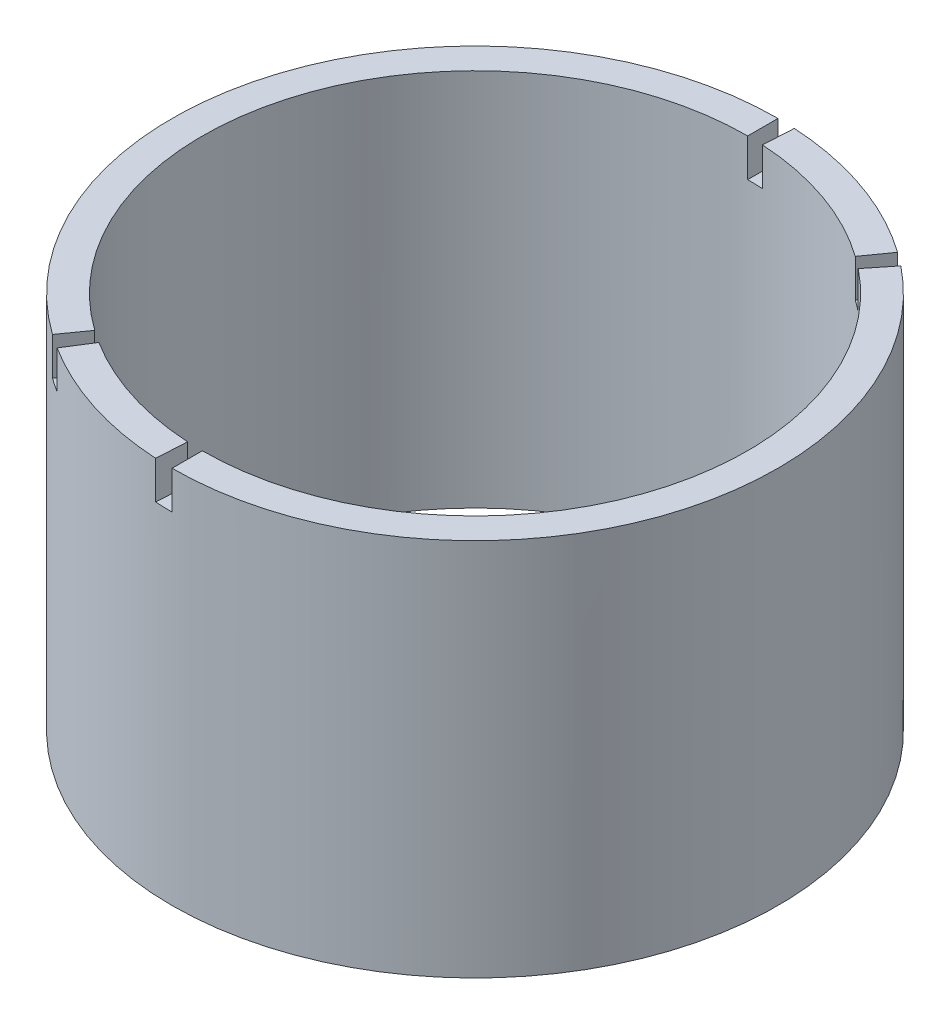
from build123d import *

# Parameters (mm, degrees)
ESQUISSE1_R      = 40
ESQUISSE1_R_2    = 36
EXTRUSION1_DEPTH = 50
EXTRUSION2_DEPTH = 5


with BuildPart() as part:
    # Esquisse1 → Extrusion1 (new body)
    with BuildSketch(Plane(origin=(0, 0, 0), x_dir=(1, 0, 0), z_dir=(0, 1, 0))):
        Circle(ESQUISSE1_R)
        Circle(ESQUISSE1_R_2, mode=Mode.SUBTRACT)
    extrude(amount=EXTRUSION1_DEPTH)

    # Esquisse2 → Extrusion2 (cut)
    with BuildSketch(Plane(origin=(0, 50, 0), x_dir=(1, 0, 0), z_dir=(0, 1, 0))):
        with BuildLine():
            Line((0, -40), (0, -36))
            ThreePointArc((0, -36), (-1.000386324, -35.986097693), (-2, -35.944401511))
            Line((-2, -35.944401511), (-2.222222222, -39.938223901))
            ThreePointArc((-2.222222222, -39.938223901), (-1.11154036, -39.984552993), (0, -40))
        make_face()
        with BuildLine():
            Line((0, 40), (0, 36))
            ThreePointArc((0, 36), (1.000386324, 35.986097693), (2, 35.944401511))
            Line((2, 35.944401511), (2.222222222, 39.938223901))
            ThreePointArc((2.222222222, 39.938223901), (1.11154036, 39.984552993), (0, 40))
        make_face()
        with BuildLine():
            Line((23.193991942, 32.588935819), (20.874592748, 29.330042237))
            ThreePointArc((20.874592748, 29.330042237), (21.68126112, 28.738874652), (22.471196895, 28.12552773))
            Line((22.471196895, 28.12552773), (24.96799655, 31.250586367))
            ThreePointArc((24.96799655, 31.250586367), (24.090290133, 31.932082947), (23.193991942, 32.588935819))
        make_face()
        with BuildLine():
            Line((-21.348400939, -33.826702135), (-19.213560845, -30.444031922))
            ThreePointArc((-19.213560845, -30.444031922), (-20.051814329, -29.898574249), (-20.874592748, -29.330042237))
            Line((-20.874592748, -29.330042237), (-23.193991942, -32.588935819))
            ThreePointArc((-23.193991942, -32.588935819), (-22.279793699, -33.220638055), (-21.348400939, -33.826702135))
        make_face()
    extrude(amount=-EXTRUSION2_DEPTH, mode=Mode.SUBTRACT)


solid = part.part
